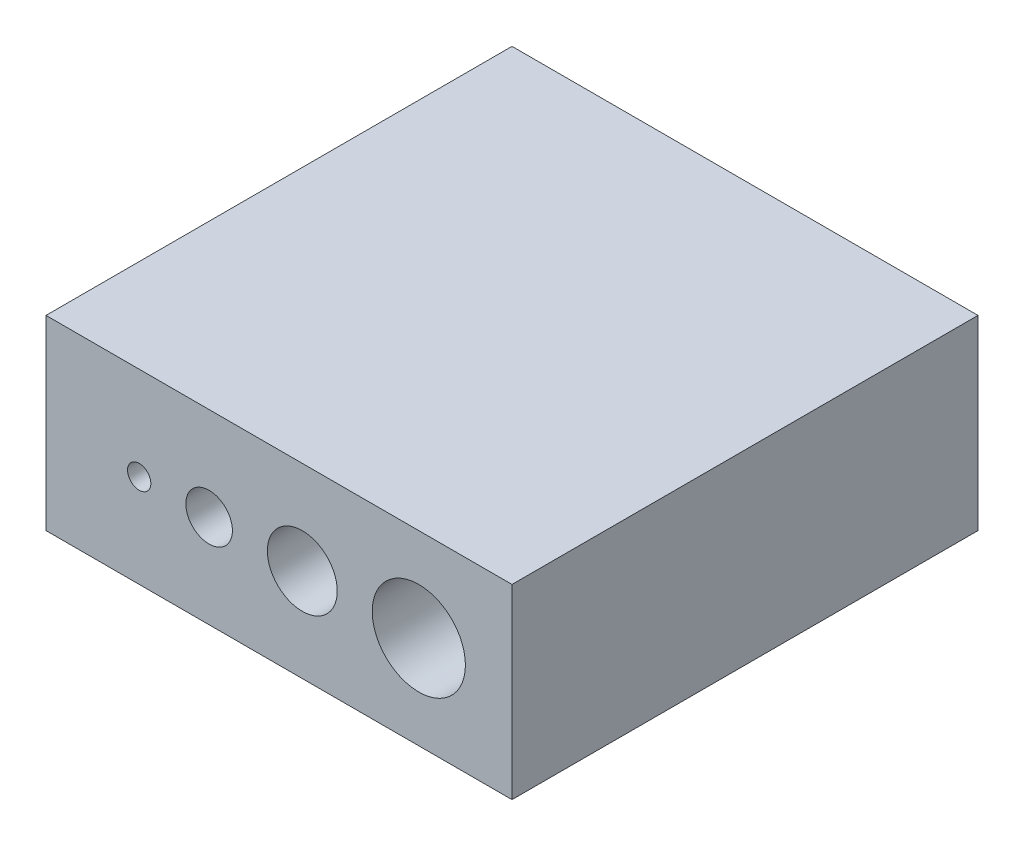
from build123d import *

# Parameters (mm, degrees)
SKETCH1_W           = 20
SKETCH1_H           = 8
BOSS_EXTRUDE1_DEPTH = 20
SKETCH2_R           = 0.5
SKETCH2_R_2         = 1
SKETCH2_R_3         = 1.5
SKETCH2_R_4         = 2
CUT_EXTRUDE1_DEPTH  = 21


with BuildPart() as part:
    # Sketch1 → Boss-Extrude1 (new body)
    with BuildSketch(Plane.XY):
        with Locations((10, 4)):
            Rectangle(SKETCH1_W, SKETCH1_H)
    extrude(amount=-BOSS_EXTRUDE1_DEPTH)

    # Sketch2 → Cut-Extrude1 (cut, through all)
    with BuildSketch(Plane.XY):
        with Locations((4, 4)):
            Circle(SKETCH2_R)
        with Locations((7, 4)):
            Circle(SKETCH2_R_2)
        with Locations((11, 4)):
            Circle(SKETCH2_R_3)
        with Locations((16, 4)):
            Circle(SKETCH2_R_4)
    extrude(amount=-CUT_EXTRUDE1_DEPTH, mode=Mode.SUBTRACT)


solid = part.part
